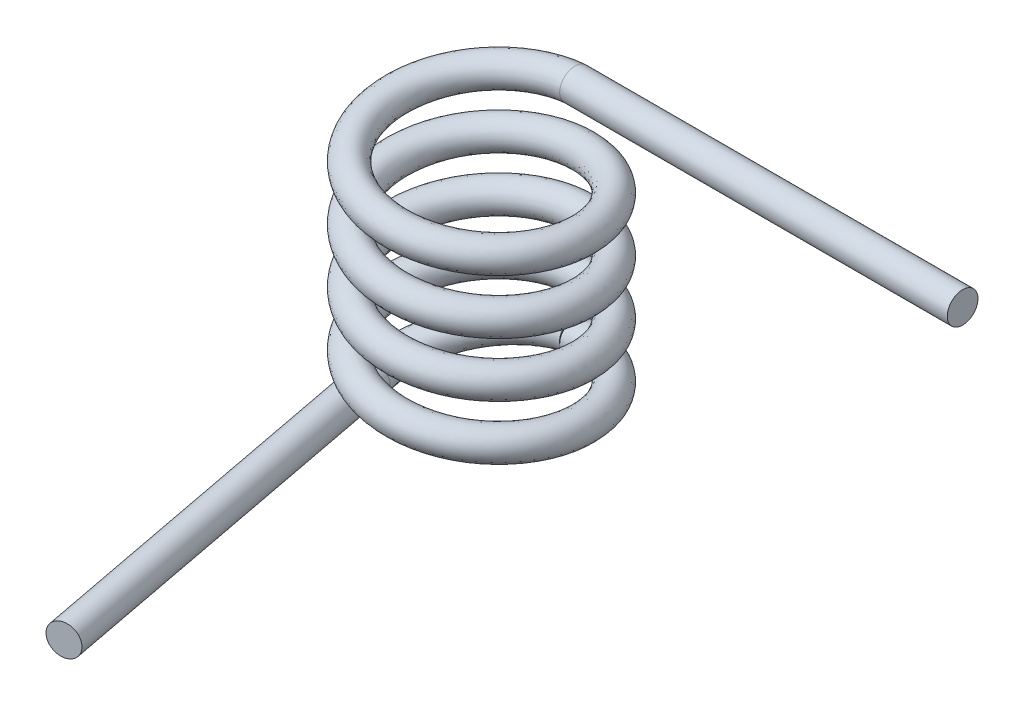
from build123d import *

# Parameters (mm, degrees)
SWEEP1_PITCH        = 1.125
SWEEP1_HEIGHT       = 4.5
SWEEP1_RADIUS       = 2
SWEEP1_START_ANGLE  = -180
SKETCH2_R           = 0.317499998
SWEEP3_PITCH        = 2.1875
SWEEP3_HEIGHT       = 0.6125
SWEEP3_RADIUS       = 2.25
SKETCH5_R           = 0.3175
SKETCH12_R          = 0.317499998
BOSS_EXTRUDE4_DEPTH = 8
SKETCH15_R          = 0.3175
BOSS_EXTRUDE7_DEPTH = 8


with BuildPart() as part:
    # Sweep1: sweep along a helix
    with BuildLine() as sweep1_path:
        add(Helix(SWEEP1_PITCH, SWEEP1_HEIGHT, SWEEP1_RADIUS, center=(0, 0, 0), direction=(0, 1, 0), lefthand=True, mode=Mode.PRIVATE).rotate(Axis((0, 0, 0), (0, 1, 0)), SWEEP1_START_ANGLE))
    # Sketch2 → Sweep1 (sweep)
    with BuildSketch(Plane(origin=(0, 0, 0), x_dir=(0, 0, -1), z_dir=(1, 0, 0))):
        with Locations((-1.93233569, 0.515828248)):
            Circle(SKETCH2_R)
    sweep(path=sweep1_path.line, is_frenet=True)

    # Sweep3: sweep along a helix
    with BuildLine() as sweep3_path:
        Helix(SWEEP3_PITCH, SWEEP3_HEIGHT, SWEEP3_RADIUS, center=(0, 0, 0), direction=(0, -1, 0), lefthand=True)
    # Sketch5 → Sweep3 (sweep)
    with BuildSketch(Plane.ZY):
        with Locations((-1.93, 0)):
            Circle(SKETCH5_R)
    sweep(path=sweep3_path.line, is_frenet=True)

    # Sketch12 → Boss-Extrude4 (add)
    with BuildSketch(Plane(origin=(0, 0, 0), x_dir=(0, 0, -1), z_dir=(1, 0, 0))):
        with Locations((1.93233569, 4.453328248)):
            Circle(SKETCH12_R)
    extrude(amount=BOSS_EXTRUDE4_DEPTH)

    # Sketch15 → Boss-Extrude7 (add)
    with BuildSketch(Plane(origin=(0, 0, 0), x_dir=(0.982303951, 0, -0.187293748), z_dir=(0.187293748, 0, 0.982303951))):
        with Locations((-1.93, -0.613166674)):
            Circle(SKETCH15_R)
    extrude(amount=BOSS_EXTRUDE7_DEPTH)


solid = part.part
